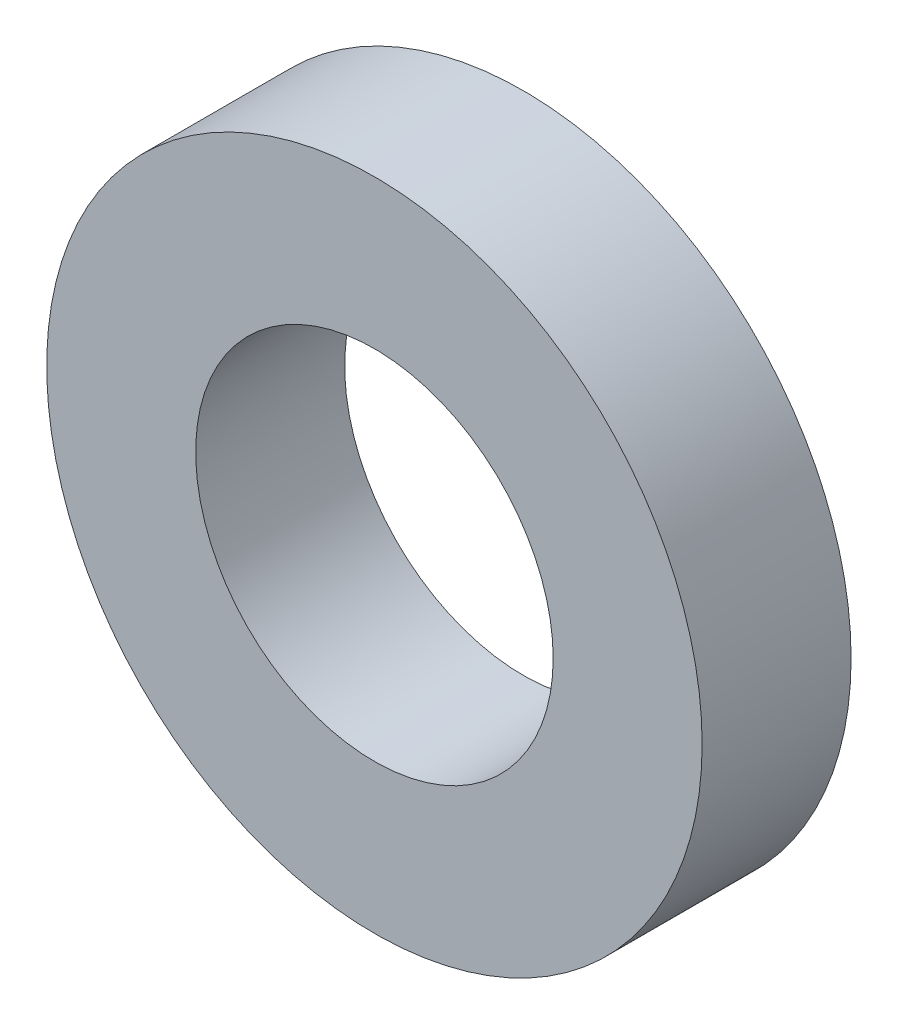
from build123d import *

# Parameters (mm, degrees)
SKETCH1_R           = 22
BOSS_EXTRUDE1_DEPTH = 10
SKETCH2_R           = 12
CUT_EXTRUDE1_DEPTH  = 25


with BuildPart() as part:
    # Sketch1 → Boss-Extrude1 (new body)
    with BuildSketch(Plane.XY):
        Circle(SKETCH1_R)
    extrude(amount=BOSS_EXTRUDE1_DEPTH)

    # Sketch2 → Cut-Extrude1 (cut)
    with BuildSketch(Plane.XY.offset(10)):
        Circle(SKETCH2_R)
    extrude(amount=-CUT_EXTRUDE1_DEPTH, mode=Mode.SUBTRACT)


solid = part.part
